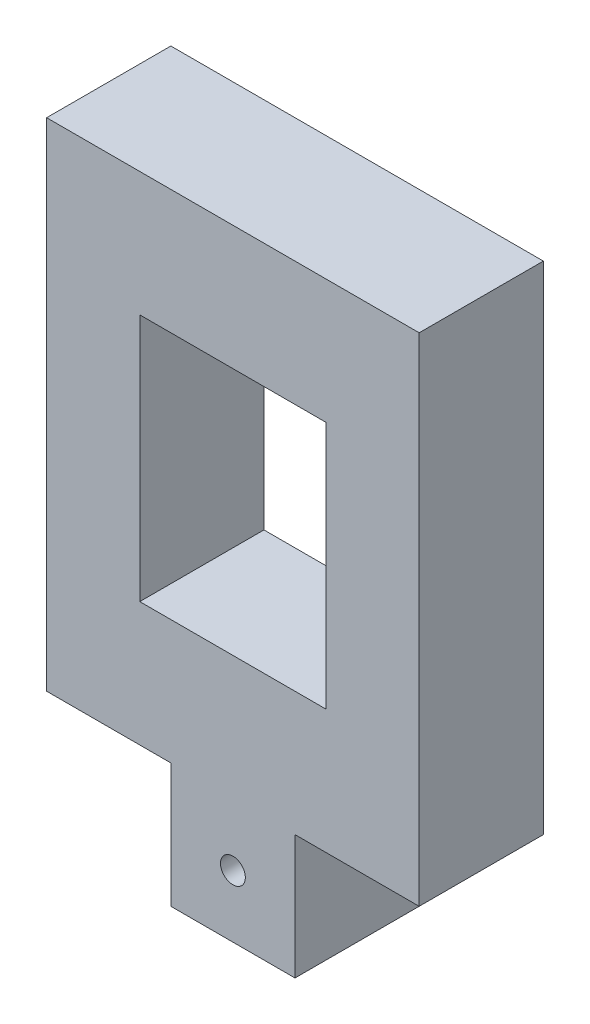
from build123d import *

# Parameters (mm, degrees)
SKETCH1_W           = 19.05
SKETCH1_H           = 31.75
BOSS_EXTRUDE1_DEPTH = 6.35
SKETCH2_W           = 9.525
SKETCH2_H           = 12.7
CUT_EXTRUDE1_DEPTH  = 6.35
SKETCH3_W           = 6.35
SKETCH3_H           = 6.35
CUT_EXTRUDE2_DEPTH  = 7.35
SKETCH4_R           = 0.635
CUT_EXTRUDE3_DEPTH  = 7.35


with BuildPart() as part:
    # Sketch1 → Boss-Extrude1 (new body)
    with BuildSketch(Plane.XY):
        with Locations((9.525, 15.875)):
            Rectangle(SKETCH1_W, SKETCH1_H)
    extrude(amount=BOSS_EXTRUDE1_DEPTH)

    # Sketch2 → Cut-Extrude1 (cut)
    with BuildSketch(Plane.XY.offset(6.35)):
        with Locations((9.525, 19.05)):
            Rectangle(SKETCH2_W, SKETCH2_H)
    extrude(amount=-CUT_EXTRUDE1_DEPTH, mode=Mode.SUBTRACT)

    # Sketch3 → Cut-Extrude2 (cut, through all)
    with BuildSketch(Plane(origin=(0, 0, 0), x_dir=(-1, 0, 0), z_dir=(0, 0, -1))):
        with Locations((-15.875, 3.175)):
            Rectangle(SKETCH3_W, SKETCH3_H)
        with Locations((-3.175, 3.175)):
            Rectangle(SKETCH3_W, SKETCH3_H)
    extrude(amount=-CUT_EXTRUDE2_DEPTH, mode=Mode.SUBTRACT)

    # Sketch4 → Cut-Extrude3 (cut, through all)
    with BuildSketch(Plane.XY.offset(6.35)):
        with Locations((9.525, 3.175)):
            Circle(SKETCH4_R)
    extrude(amount=-CUT_EXTRUDE3_DEPTH, mode=Mode.SUBTRACT)


solid = part.part
